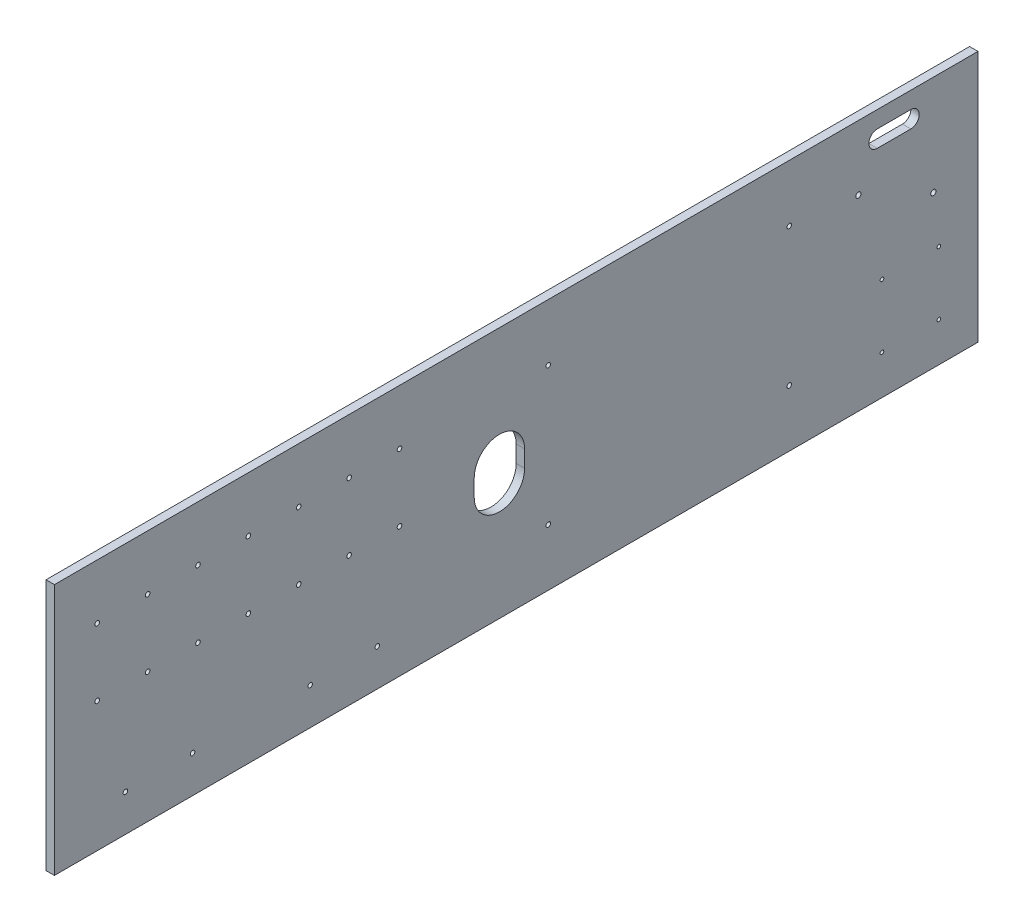
from build123d import *

# Parameters (mm, degrees)
BOSS_EXTRUDE1_DEPTH = 6.35
SKETCH2_R           = 1.7272
SKETCH2_R_2         = 1.3890625
SKETCH2_R_3         = 1.984375
CUT_EXTRUDE1_DEPTH  = 7.35


with BuildPart() as part:
    # Sketch1 → Boss-Extrude1 (new body)
    with BuildSketch(Plane(origin=(0, 0, 0), x_dir=(0, 0, -1), z_dir=(1, 0, 0))):
        Polygon((146.05, 95.25), (158.75, 95.25), (552.45, 95.25), (552.45, -95.25), (158.75, -95.25), (146.05, -95.25), (-146.05, -95.25), (-146.05, 95.25), align=None)
    extrude(amount=BOSS_EXTRUDE1_DEPTH)

    # Sketch2 → Cut-Extrude1 (cut, through all)
    with BuildSketch(Plane.ZY):
        with Locations((113.660651072, 53.713174026)):
            Circle(SKETCH2_R)
        with Locations((75.560651072, 53.713174026)):
            Circle(SKETCH2_R)
        with Locations((37.460651072, 53.713174026)):
            Circle(SKETCH2_R)
        with Locations((-0.639348928, 53.713174026)):
            Circle(SKETCH2_R)
        with Locations((-38.739348928, 53.713174026)):
            Circle(SKETCH2_R)
        with Locations((-76.839348928, 53.713174026)):
            Circle(SKETCH2_R)
        with Locations((-114.939348928, 53.713174026)):
            Circle(SKETCH2_R)
        with Locations((-114.939348928, 2.913174026)):
            Circle(SKETCH2_R)
        with Locations((-76.839348928, 2.913174026)):
            Circle(SKETCH2_R)
        with Locations((-38.739348928, 2.913174026)):
            Circle(SKETCH2_R)
        with Locations((-0.639348928, 2.913174026)):
            Circle(SKETCH2_R)
        with Locations((37.460651072, 2.913174026)):
            Circle(SKETCH2_R)
        with Locations((75.560651072, 2.913174026)):
            Circle(SKETCH2_R)
        with Locations((113.660651072, 2.913174026)):
            Circle(SKETCH2_R)
        with Locations((92.336825974, -67.314348928)):
            Circle(SKETCH2_R)
        with Locations((41.536825974, -67.314348928)):
            Circle(SKETCH2_R)
        with Locations((-47.363174026, -67.314348928)):
            Circle(SKETCH2_R)
        with Locations((-98.163174026, -67.314348928)):
            Circle(SKETCH2_R)
        with Locations((-227.452489037, 52.197)):
            Circle(SKETCH2_R)
        with Locations((-227.452489037, -52.197)):
            Circle(SKETCH2_R)
        with Locations((-409.722889037, -52.197)):
            Circle(SKETCH2_R)
        with Locations((-409.722889037, 52.197)):
            Circle(SKETCH2_R)
        with Locations((-522.859, -17.782353467)):
            Circle(SKETCH2_R_2)
        with Locations((-479.806, -17.78)):
            Circle(SKETCH2_R_2)
        with Locations((-479.806, -65.532)):
            Circle(SKETCH2_R_2)
        with Locations((-522.859, -65.532)):
            Circle(SKETCH2_R_2)
        with Locations((-462.026, 46.355)):
            Circle(SKETCH2_R_3)
        with Locations((-518.668, 19.685)):
            Circle(SKETCH2_R_3)
        with BuildLine():
            Line((-501.65, 82.55), (-476.25, 82.55))
            ThreePointArc((-476.25, 82.55), (-469.9, 76.2), (-476.25, 69.85))
            Line((-476.25, 69.85), (-501.65, 69.85))
            ThreePointArc((-501.65, 69.85), (-508, 76.2), (-501.65, 82.55))
        make_face()
        with BuildLine():
            Line((-171.45, 6.35), (-171.45, -6.35))
            ThreePointArc((-171.45, -6.35), (-190.5, -25.4), (-209.55, -6.35))
            Line((-209.55, -6.35), (-209.55, 6.35))
            ThreePointArc((-209.55, 6.35), (-190.5, 25.4), (-171.45, 6.35))
        make_face()
    extrude(amount=-CUT_EXTRUDE1_DEPTH, mode=Mode.SUBTRACT)


solid = part.part
